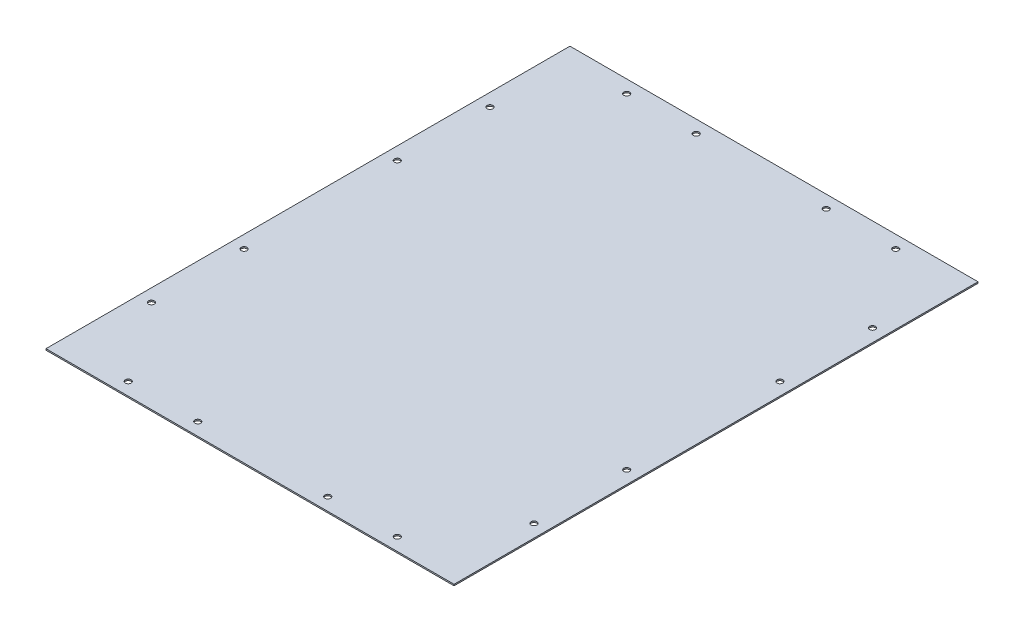
from build123d import *

# Parameters (mm, degrees)
SURFACE_EXTRUDE1_1_DEPTH = 352.2
THICKEN1_T1              = 1.2
SKETCH2_R                = 2.5
CUT_EXTRUDE1_DEPTH       = 10


with BuildPart() as body_1:
    # Surface-Extrude1: a surface, the sketch's curves swept straight by 352.2 mm
    with BuildLine(Plane(origin=(0, 0, 0), x_dir=(0, 0, -1), z_dir=(1, 0, 0)), mode=Mode.PRIVATE) as surface_extrude1_1_path:
        Line((0, 0), (452.2, 0))
    surface_extrude1_1 = Shell.extrude(surface_extrude1_1_path.wire(), (1 * SURFACE_EXTRUDE1_1_DEPTH, 0 * SURFACE_EXTRUDE1_1_DEPTH, 0 * SURFACE_EXTRUDE1_1_DEPTH))
    add(Solid.thicken(surface_extrude1_1, THICKEN1_T1))

    # Sketch2 → Cut-Extrude1 (cut)
    with BuildSketch(Plane(origin=(0, 1.2, 0), x_dir=(1, 0, 0), z_dir=(0, 1, 0))):
        with Locations(Location((60, 441.2, 0), (0, 0, 270))):
            Circle(SKETCH2_R)
        with Locations(Location((120, 441.2, 0), (0, 0, 270))):
            Circle(SKETCH2_R)
        with Locations(Location((11, 372.2, 0), (0, 0, 270))):
            Circle(SKETCH2_R)
        with Locations(Location((11, 292.2, 0), (0, 0, 270))):
            Circle(SKETCH2_R)
        with Locations(Location((341.2, 292.2, 0), (0, 0, 90))):
            Circle(SKETCH2_R)
        with Locations(Location((341.2, 372.2, 0), (0, 0, 90))):
            Circle(SKETCH2_R)
        with Locations(Location((292.2, 441.2, 0), (0, 0, 90))):
            Circle(SKETCH2_R)
        with Locations(Location((232.2, 441.2, 0), (0, 0, 90))):
            Circle(SKETCH2_R)
        with Locations(Location((11, 160, 0), (0, 0, 90))):
            Circle(SKETCH2_R)
        with Locations(Location((11, 80, 0), (0, 0, 90))):
            Circle(SKETCH2_R)
        with Locations(Location((60, 11, 0), (0, 0, 90))):
            Circle(SKETCH2_R)
        with Locations(Location((120, 11, 0), (0, 0, 90))):
            Circle(SKETCH2_R)
        with Locations(Location((232.2, 11, 0), (0, 0, 270))):
            Circle(SKETCH2_R)
        with Locations(Location((292.2, 11, 0), (0, 0, 270))):
            Circle(SKETCH2_R)
        with Locations(Location((341.2, 80, 0), (0, 0, 270))):
            Circle(SKETCH2_R)
        with Locations(Location((341.2, 160, 0), (0, 0, 270))):
            Circle(SKETCH2_R)
    extrude(amount=-CUT_EXTRUDE1_DEPTH, mode=Mode.SUBTRACT)


solid = body_1.part
